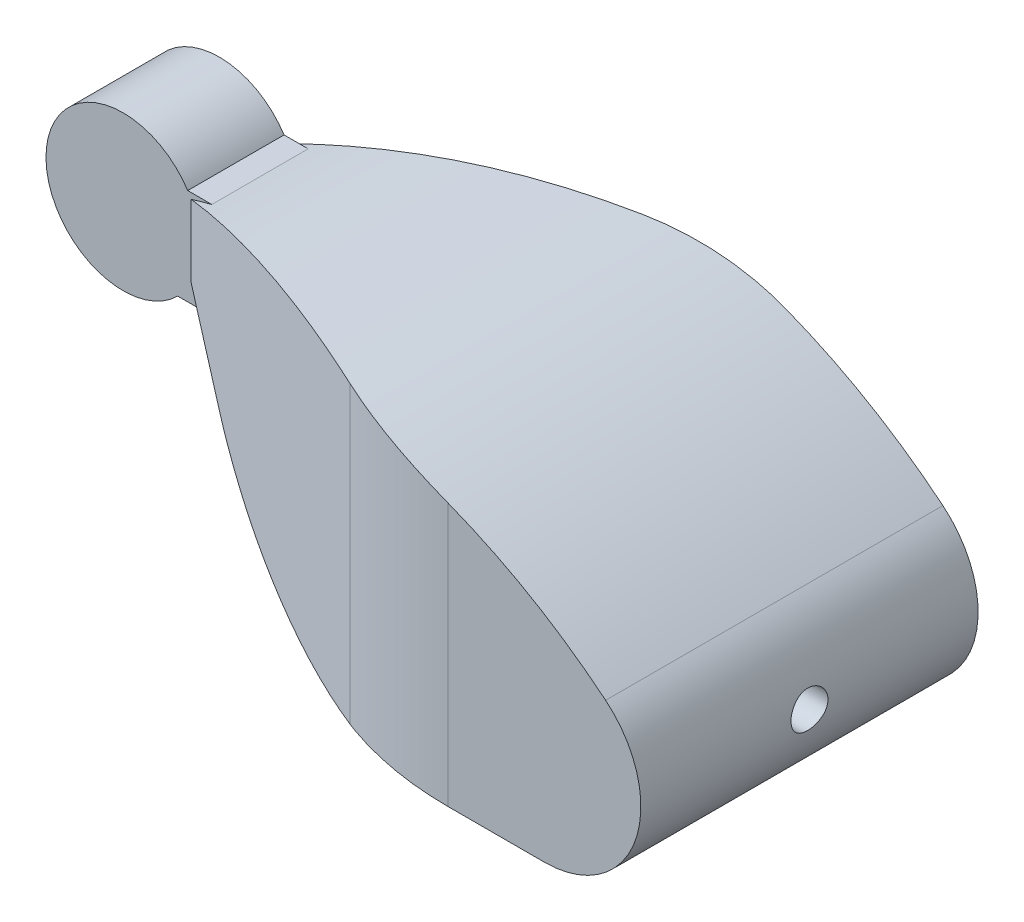
from build123d import *

# Parameters (mm, degrees)
BOSS_EXTRUDE1_DEPTH             = 6.35
BOSS_EXTRUDE3_START             = -7.9375
BOSS_EXTRUDE3_DEPTH             = 22.225
CUT_EXTRUDE4_DEPTH              = 6.08
CUT_EXTRUDE4_DEPTH_BACK         = 16.875
CUT_EXTRUDE10_START             = -19.05
SKETCH16_W                      = 4.7625
SKETCH16_H                      = 4.7625
CUT_EXTRUDE10_DEPTH             = 29.091259281
CUT_EXTRUDE11_REACH             = 13.113
CUT_EXTRUDE11_DIRECTION_2_REACH = 13.113
F_2_CLEARANCE_HOLE1_D           = 2.4384
BOSS_EXTRUDE19_DEPTH            = 6.35
CUT_EXTRUDE12_DEPTH             = 4.7625
CUT_EXTRUDE12_DEPTH_BACK        = 4.7625
CUT_EXTRUDE13_DEPTH             = 3.175
CUT_EXTRUDE14_START             = 9.525
CUT_EXTRUDE14_DEPTH             = 3.175


with BuildPart() as part:
    # Sketch2 → Boss-Extrude1 (new body)
    with BuildSketch(Plane.XY):
        with BuildLine():
            Line((4.487320853, -2.38125), (4.487320853, 2.38125))
            ThreePointArc((4.487320853, 2.38125), (-5.08, 0), (4.487320853, -2.38125))
        make_face()
    extrude(amount=BOSS_EXTRUDE1_DEPTH)

    # Sketch3 → Boss-Extrude3 (add)
    with BuildSketch(Plane.XY.offset(BOSS_EXTRUDE3_START)):
        with BuildLine():
            Line((4.487320853, 2.38125), (4.487320853, -2.38125))
            Line((4.487320853, -2.38125), (7.464780529, -7.539384784))
            ThreePointArc((7.464780529, -7.539384784), (13.566062361, -13.641452925), (21.901057446, -15.875))
            Line((21.901057446, -15.875), (35.711259281, -15.875))
            ThreePointArc((35.711259281, -15.875), (41.690195135, -11.663884303), (39.7390552, -4.615890098))
            ThreePointArc((39.7390552, -4.615890098), (22.990060642, 3.300382048), (4.487320853, 2.38125))
        make_face()
    extrude(amount=BOSS_EXTRUDE3_DEPTH)

    # Sketch14 → Cut-Extrude4 (cut, two sides)
    with BuildSketch(Plane(origin=(0, 0, 0), x_dir=(1, 0, 0), z_dir=(0, 1, 0))) as cut_extrude4_sk:
        with BuildLine():
            Line((4.487320853, -6.35), (21.428093277, -12.823412845))
            ThreePointArc((21.428093277, -12.823412845), (25.327691566, -13.918413536), (29.361259281, -14.2875))
            Line((29.361259281, -14.2875), (4.487320853, -14.2875))
            Line((4.487320853, -14.2875), (4.487320853, -6.35))
        make_face()
        with BuildLine():
            Line((4.487320853, 0), (21.428093277, 6.473412845))
            ThreePointArc((21.428093277, 6.473412845), (25.327691566, 7.568413536), (29.361259281, 7.9375))
            Line((29.361259281, 7.9375), (4.487320853, 7.9375))
            Line((4.487320853, 7.9375), (4.487320853, 0))
        make_face()
    extrude(amount=CUT_EXTRUDE4_DEPTH, mode=Mode.SUBTRACT)
    extrude(cut_extrude4_sk.sketch, amount=-CUT_EXTRUDE4_DEPTH_BACK, mode=Mode.SUBTRACT)

    # Sketch16 → Cut-Extrude10 (cut, through all)
    with BuildSketch(Plane(origin=(42.061259281, 0, 0), x_dir=(0, 0, -1), z_dir=(1, 0, 0)).offset(CUT_EXTRUDE10_START)):
        with Locations((-3.175, -9.58215)):
            Rectangle(SKETCH16_W, SKETCH16_H)
    extrude(amount=-CUT_EXTRUDE10_DEPTH, mode=Mode.SUBTRACT)

    # Cut-Extrude11: up to this face of the body (flat: up to its plane)
    cut_extrude11_end = Plane(part.part.faces().sort_by_distance((15.949219939, -9.473187723, 5.55625))[0])
    # Sketch29 → Cut-Extrude11 (cut, up to the picked face)
    with BuildSketch(Plane(origin=(0, 0, 3.175), x_dir=(-1, 0, 0), z_dir=(0, 0, -1)), mode=Mode.PRIVATE) as cut_extrude11_sk1:
        Polygon((-7.269395019, -7.2009), (-23.011259281, -7.2009), (-6.432122374, -5.75041347), align=None)
    cut_extrude11_tool1 = split(extrude(cut_extrude11_sk1.sketch, amount=-CUT_EXTRUDE11_REACH, mode=Mode.PRIVATE), bisect_by=cut_extrude11_end, keep=Keep.BOTH, mode=Mode.PRIVATE)
    add(cut_extrude11_tool1.solids().sort_by_distance((12.237592, -6.717404, 3.175))[0], mode=Mode.SUBTRACT)
    # Sketch29 → Cut-Extrude11 (cut, up to the picked face)
    with BuildSketch(Plane(origin=(0, 0, 3.175), x_dir=(-1, 0, 0), z_dir=(0, 0, -1)), mode=Mode.PRIVATE) as cut_extrude11_sk2:
        with BuildLine():
            Line((-23.011259281, -11.9634), (-13.549349632, -13.63178996))
            ThreePointArc((-13.549349632, -13.63178996), (-12.324513592, -12.849454696), (-11.172481099, -11.9634))
            Line((-11.172481099, -11.9634), (-23.011259281, -11.9634))
        make_face()
    cut_extrude11_tool2 = split(extrude(cut_extrude11_sk2.sketch, amount=-CUT_EXTRUDE11_REACH, mode=Mode.PRIVATE), bisect_by=cut_extrude11_end, keep=Keep.BOTH, mode=Mode.PRIVATE)
    add(cut_extrude11_tool2.solids().sort_by_distance((15.867281, -12.523197, 3.175))[0], mode=Mode.SUBTRACT)

    # Cut-Extrude11 direction 2: up to this face of the body (flat: up to its plane)
    cut_extrude11_direction_2_end = Plane(part.part.faces().sort_by_distance((15.949219939, -9.473187723, 0.79375))[0])
    # Sketch29 → Cut-Extrude11 direction 2 (cut, up to the picked face)
    with BuildSketch(Plane(origin=(0, 0, 3.175), x_dir=(-1, 0, 0), z_dir=(0, 0, -1)), mode=Mode.PRIVATE) as cut_extrude11_direction_2_sk1:
        Polygon((-7.269395019, -7.2009), (-23.011259281, -7.2009), (-6.432122374, -5.75041347), align=None)
    cut_extrude11_direction_2_tool1 = split(extrude(cut_extrude11_direction_2_sk1.sketch, amount=CUT_EXTRUDE11_DIRECTION_2_REACH, mode=Mode.PRIVATE), bisect_by=cut_extrude11_direction_2_end, keep=Keep.BOTH, mode=Mode.PRIVATE)
    add(cut_extrude11_direction_2_tool1.solids().sort_by_distance((12.237592, -6.717404, 3.175))[0], mode=Mode.SUBTRACT)
    # Sketch29 → Cut-Extrude11 direction 2 (cut, up to the picked face)
    with BuildSketch(Plane(origin=(0, 0, 3.175), x_dir=(-1, 0, 0), z_dir=(0, 0, -1)), mode=Mode.PRIVATE) as cut_extrude11_direction_2_sk2:
        with BuildLine():
            Line((-23.011259281, -11.9634), (-13.549349632, -13.63178996))
            ThreePointArc((-13.549349632, -13.63178996), (-12.324513592, -12.849454696), (-11.172481099, -11.9634))
            Line((-11.172481099, -11.9634), (-23.011259281, -11.9634))
        make_face()
    cut_extrude11_direction_2_tool2 = split(extrude(cut_extrude11_direction_2_sk2.sketch, amount=CUT_EXTRUDE11_DIRECTION_2_REACH, mode=Mode.PRIVATE), bisect_by=cut_extrude11_direction_2_end, keep=Keep.BOTH, mode=Mode.PRIVATE)
    add(cut_extrude11_direction_2_tool2.solids().sort_by_distance((15.867281, -12.523197, 3.175))[0], mode=Mode.SUBTRACT)

    # 2 Clearance Hole1 (through all)
    with Locations(Plane.ZY.offset(-23.011259281)):
        with Locations((3.175, -9.58215)):
            Hole(F_2_CLEARANCE_HOLE1_D / 2)

    # Sketch25 → Boss-Extrude19 (add)
    with BuildSketch(Plane.XY.offset(6.35)):
        with BuildLine():
            Line((5.183826817, -3.587873106), (4.487320853, -2.38125))
            ThreePointArc((4.487320853, -2.38125), (4.086603081, -3.017627422), (3.596326817, -3.587873106))
            Line((3.596326817, -3.587873106), (5.183826817, -3.587873106))
        make_face()
        with BuildLine():
            Line((4.259998652, 2.767455779), (5.847498652, 2.767455779))
            ThreePointArc((5.847498652, 2.767455779), (5.165618018, 2.580663195), (4.487320853, 2.38125))
            ThreePointArc((4.487320853, 2.38125), (4.377920551, 2.576860812), (4.259998652, 2.767455779))
        make_face()
    extrude(amount=-BOSS_EXTRUDE19_DEPTH)

    # Sketch32 → Cut-Extrude12 (cut, two sides)
    with BuildSketch(Plane(origin=(0, 0, 3.175), x_dir=(-1, 0, 0), z_dir=(0, 0, -1))) as cut_extrude12_sk:
        with BuildLine():
            Line((-29.361259281, -15.875), (-21.901057446, -15.875))
            ThreePointArc((-21.901057446, -15.875), (-21.664551554, -15.873322074), (-21.428093277, -15.868288634))
            ThreePointArc((-21.428093277, -15.868288634), (-17.349223696, -15.24146238), (-13.549349632, -13.63178996))
            Line((-13.549349632, -13.63178996), (-16.19315137, -13.165616382))
            ThreePointArc((-16.19315137, -13.165616382), (-18.992500475, -14.004371432), (-21.901057446, -14.2875))
            Line((-21.901057446, -14.2875), (-35.711259281, -14.2875))
            ThreePointArc((-35.711259281, -14.2875), (-37.533789128, -13.924976274), (-39.078855326, -12.892596045))
            Line((-39.078855326, -12.892596045), (-40.201387342, -14.015128061))
            ThreePointArc((-40.201387342, -14.015128061), (-38.141299077, -15.391635031), (-35.711259281, -15.875))
            Line((-35.711259281, -15.875), (-29.361259281, -15.875))
        make_face()
    extrude(amount=CUT_EXTRUDE12_DEPTH, mode=Mode.SUBTRACT)
    extrude(cut_extrude12_sk.sketch, amount=-CUT_EXTRUDE12_DEPTH_BACK, mode=Mode.SUBTRACT)

    # Sketch33 → Cut-Extrude13 (cut)
    with BuildSketch(Plane(origin=(0, 0, 7.9375), x_dir=(-1, 0, 0), z_dir=(0, 0, -1))):
        with BuildLine():
            Line((-21.901057446, -15.875), (-21.901057446, -14.2875))
            Line((-21.901057446, -14.2875), (-35.711259281, -14.2875))
            ThreePointArc((-35.711259281, -14.2875), (-37.533789128, -13.924976274), (-39.078855326, -12.892596045))
            Line((-39.078855326, -12.892596045), (-40.201387342, -14.015128061))
            ThreePointArc((-40.201387342, -14.015128061), (-38.141299077, -15.391635031), (-35.711259281, -15.875))
            Line((-35.711259281, -15.875), (-21.901057446, -15.875))
        make_face()
    extrude(amount=-CUT_EXTRUDE13_DEPTH, mode=Mode.SUBTRACT)

    # Sketch33_2 → Cut-Extrude14 (cut)
    with BuildSketch(Plane(origin=(0, 0, 7.9375), x_dir=(-1, 0, 0), z_dir=(0, 0, -1)).offset(CUT_EXTRUDE14_START)):
        with BuildLine():
            Line((-35.711259281, -15.875), (-21.901057446, -15.875))
            Line((-21.901057446, -15.875), (-21.901057446, -14.2875))
            Line((-21.901057446, -14.2875), (-35.711259281, -14.2875))
            ThreePointArc((-35.711259281, -14.2875), (-37.533789128, -13.924976274), (-39.078855326, -12.892596045))
            Line((-39.078855326, -12.892596045), (-40.201387342, -14.015128061))
            ThreePointArc((-40.201387342, -14.015128061), (-38.141299077, -15.391635031), (-35.711259281, -15.875))
        make_face()
    extrude(amount=CUT_EXTRUDE14_DEPTH, mode=Mode.SUBTRACT)


solid = part.part
